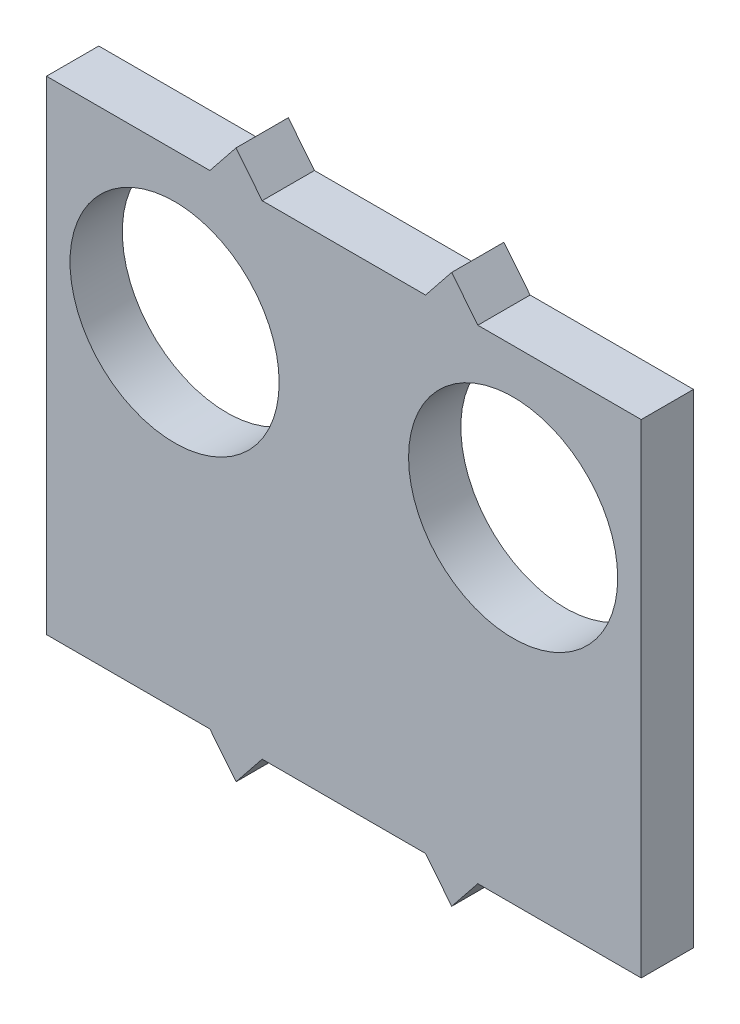
from build123d import *

# Parameters (mm, degrees)
SKETCH1_W      = 45.5
SKETCH1_H      = 37
BASIS_DEPTH    = 4
SKETCH3_R      = 8
HR04_GAT_DEPTH = 4


with BuildPart() as part:
    # Sketch1 → Basis (new body)
    with BuildSketch(Plane.XY):
        with Locations((22.75, 18.5)):
            Rectangle(SKETCH1_W, SKETCH1_H)
        Polygon((14.5, 39.5), (12.5, 37), (16.5, 37), align=None)
        Polygon((31, 39.5), (29, 37), (33, 37), align=None)
        Polygon((16.5, 0), (12.5, 0), (14.5, -2.5), align=None)
        Polygon((33, 0), (29, 0), (31, -2.5), align=None)
    extrude(amount=BASIS_DEPTH)

    # Sketch3 → HR04 gat (cut)
    with BuildSketch(Plane.XY.offset(4)):
        with Locations((9.8, 25.6)):
            Circle(SKETCH3_R)
        with Locations((35.7, 25.6)):
            Circle(SKETCH3_R)
    extrude(amount=-HR04_GAT_DEPTH, mode=Mode.SUBTRACT)


solid = part.part
